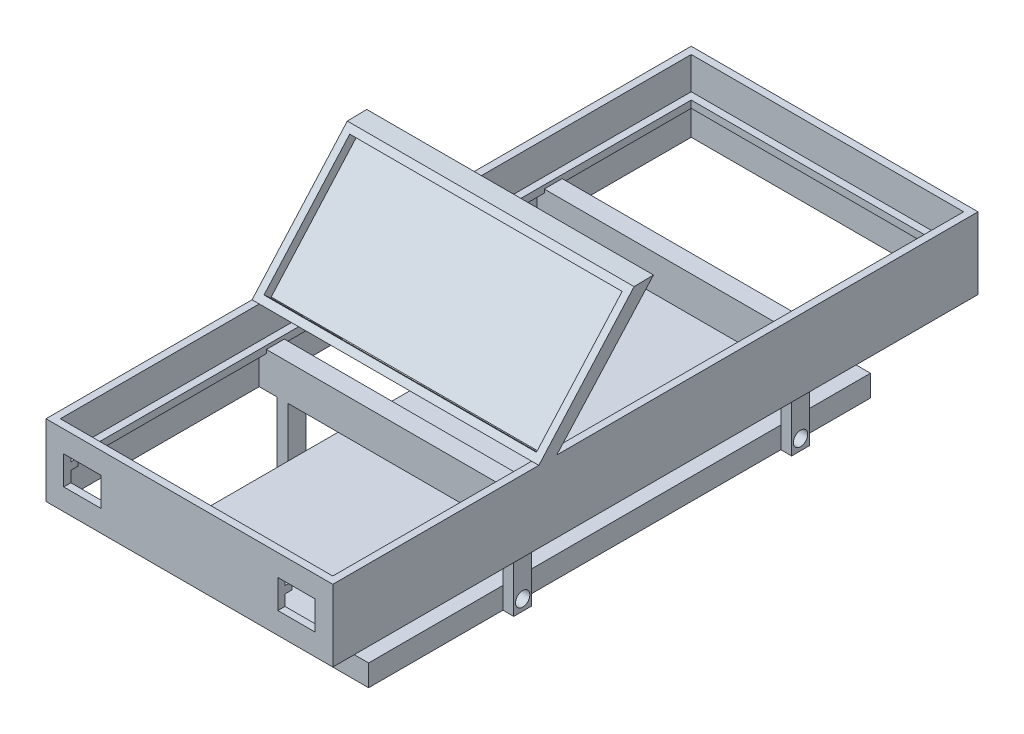
from build123d import *

# Parameters (mm, degrees)
SKETCH1_W            = 101.6
SKETCH1_H            = 50.8
BOSS_EXTRUDE1_DEPTH  = 228.6
SKETCH2_W            = 96.52
SKETCH2_H            = 172.72
CUT_EXTRUDE1_DEPTH   = 50.8
BOSS_EXTRUDE2_DEPTH  = 50.8
BOSS_EXTRUDE3_DEPTH  = 101.6
SKETCH13_W           = 96.52
SKETCH13_H           = 25.4
CUT_EXTRUDE2_DEPTH   = 50.8
SKETCH14_W           = 96.52
SKETCH14_H           = 25.4
CUT_EXTRUDE3_DEPTH   = 50.8
SKETCH15_W           = 96.52
SKETCH15_H           = 50.8
CUT_EXTRUDE6_DEPTH   = 6.35
SKETCH16_W           = 96.52
SKETCH16_H           = 45.72
CUT_EXTRUDE7_DEPTH   = 3.175
SKETCH17_W           = 101.6
SKETCH17_H           = 25.4
CUT_EXTRUDE8_DEPTH   = 228.6
SKETCH19_W           = 6.35
SKETCH19_H           = 12.7
BOSS_EXTRUDE4_DEPTH  = 96.52
SKETCH20_W           = 6.35
SKETCH20_H           = 12.7
BOSS_EXTRUDE5_DEPTH  = 101.6
SKETCH24_W           = 12.7
SKETCH24_H           = 6.35
BOSS_EXTRUDE8_DEPTH  = 19.05
SKETCH25_W           = 12.7
SKETCH25_H           = 6.35
BOSS_EXTRUDE9_DEPTH  = 19.05
SKETCH26_W           = 12.7
SKETCH26_H           = 6.35
BOSS_EXTRUDE10_DEPTH = 19.05
SKETCH27_W           = 12.7
SKETCH27_H           = 6.35
BOSS_EXTRUDE11_DEPTH = 19.05
SKETCH28_W           = 8.89
SKETCH28_H           = 19.05
CUT_EXTRUDE9_DEPTH   = 6.35
SKETCH29_W           = 8.89
SKETCH29_H           = 19.05
CUT_EXTRUDE10_DEPTH  = 6.35
SKETCH30_W           = 8.89
SKETCH30_H           = 19.05
CUT_EXTRUDE11_DEPTH  = 6.35
SKETCH31_W           = 8.89
SKETCH31_H           = 19.05
CUT_EXTRUDE12_DEPTH  = 6.35
SKETCH33_W           = 96.52
SKETCH33_H           = 2.54
BOSS_EXTRUDE13_DEPTH = 2.54
SKETCH34_W           = 96.52
SKETCH34_H           = 2.54
BOSS_EXTRUDE17_DEPTH = 2.54
SKETCH36_W           = 218.44
SKETCH36_H           = 2.54
BOSS_EXTRUDE18_DEPTH = 2.54
SKETCH37_W           = 218.44
SKETCH37_H           = 2.54
BOSS_EXTRUDE19_DEPTH = 2.54
SKETCH42_W           = 6.35
SKETCH42_H           = 6.35
CUT_EXTRUDE16_DEPTH  = 5.08
SKETCH45_W           = 13.208
SKETCH45_H           = 10.16
CUT_EXTRUDE19_DEPTH  = 6.35
SKETCH50_W           = 6.35
SKETCH50_H           = 6.35
BOSS_EXTRUDE20_DEPTH = 3.81
SKETCH51_W           = 6.35
SKETCH51_H           = 6.35
BOSS_EXTRUDE21_DEPTH = 3.81
SKETCH52_W           = 6.35
SKETCH52_H           = 6.35
BOSS_EXTRUDE22_DEPTH = 3.81
SKETCH53_W           = 6.35
SKETCH53_H           = 6.35
BOSS_EXTRUDE23_DEPTH = 3.81
SKETCH54_W           = 6.35
SKETCH54_H           = 6.35
BOSS_EXTRUDE24_DEPTH = 3.81
SKETCH55_W           = 76.2
SKETCH55_H           = 177.8
BOSS_EXTRUDE25_DEPTH = 7.62
SKETCH56_R           = 2.54
CUT_EXTRUDE20_DEPTH  = 83.82
SKETCH57_R           = 2.54
CUT_EXTRUDE21_DEPTH  = 83.82


with BuildPart() as part:
    # Sketch1 → Boss-Extrude1 (new body)
    with BuildSketch(Plane.XY):
        Rectangle(SKETCH1_W, SKETCH1_H)
    extrude(amount=-BOSS_EXTRUDE1_DEPTH)

    # Sketch2 → Cut-Extrude1 (cut)
    with BuildSketch(Plane(origin=(0, 25.4, 0), x_dir=(1, 0, 0), z_dir=(0, 1, 0))):
        with Locations((0, 114.3)):
            Rectangle(SKETCH2_W, SKETCH2_H)
    extrude(amount=-CUT_EXTRUDE1_DEPTH, mode=Mode.SUBTRACT)

    # Sketch3 → Boss-Extrude2 (add)
    with BuildSketch(Plane(origin=(0, 25.4, 0), x_dir=(1, 0, 0), z_dir=(0, 1, 0))):
        Polygon((48.26, 73.001295984), (48.26, 79.351295984), (-48.26, 79.351295984), (-48.26, 73.001295984), (0, 73.001295984), align=None)
    extrude(amount=-BOSS_EXTRUDE2_DEPTH)

    # Sketch11 → Boss-Extrude3 (add)
    with BuildSketch(Plane.ZY.offset(50.8)):
        Polygon((-79.351295984, 25.4), (-113.622558301, 63.5), (-106.756614843, 63.363382999), (-73.001295984, 25.4), align=None)
    extrude(amount=-BOSS_EXTRUDE3_DEPTH)

    # Sketch13 → Cut-Extrude2 (cut)
    with BuildSketch(Plane(origin=(0, 25.4, 0), x_dir=(1, 0, 0), z_dir=(0, 1, 0))):
        with Locations((0, 213.36)):
            Rectangle(SKETCH13_W, SKETCH13_H)
    extrude(amount=-CUT_EXTRUDE2_DEPTH, mode=Mode.SUBTRACT)

    # Sketch14 → Cut-Extrude3 (cut)
    with BuildSketch(Plane(origin=(0, 25.4, 0), x_dir=(1, 0, 0), z_dir=(0, 1, 0))):
        with Locations((0, 15.24)):
            Rectangle(SKETCH14_W, SKETCH14_H)
    extrude(amount=-CUT_EXTRUDE3_DEPTH, mode=Mode.SUBTRACT)

    # Sketch15 → Cut-Extrude6 (cut)
    with BuildSketch(Plane.XY.offset(-73.001295984)):
        Rectangle(SKETCH15_W, SKETCH15_H)
    extrude(amount=-CUT_EXTRUDE6_DEPTH, mode=Mode.SUBTRACT)

    # Sketch16 → Cut-Extrude7 (cut)
    with BuildSketch(Plane(origin=(0, -25.035409247, -28.156416881), x_dir=(1, 0, 0), z_dir=(0, 0.664474781, 0.747310689))):
        with Locations((0, 92.889211639)):
            Rectangle(SKETCH16_W, SKETCH16_H)
    extrude(amount=-CUT_EXTRUDE7_DEPTH, mode=Mode.SUBTRACT)

    # Sketch17 → Cut-Extrude8 (cut)
    with BuildSketch(Plane.XY):
        with Locations((0, -12.7)):
            Rectangle(SKETCH17_W, SKETCH17_H)
    extrude(amount=-CUT_EXTRUDE8_DEPTH, mode=Mode.SUBTRACT)

    # Sketch19 → Boss-Extrude4 (add)
    with BuildSketch(Plane.ZY.offset(-48.26)):
        with Locations((-76.176295984, 6.35)):
            Rectangle(SKETCH19_W, SKETCH19_H)
    extrude(amount=BOSS_EXTRUDE4_DEPTH)

    # Sketch20 → Boss-Extrude5 (add)
    with BuildSketch(Plane.ZY.offset(50.8)):
        with Locations((-174.625, 6.35)):
            Rectangle(SKETCH20_W, SKETCH20_H)
    extrude(amount=-BOSS_EXTRUDE5_DEPTH)

    # Sketch24 → Boss-Extrude8 (add)
    with BuildSketch(Plane.XZ):
        with Locations((44.45, -76.176295984)):
            Rectangle(SKETCH24_W, SKETCH24_H)
    extrude(amount=BOSS_EXTRUDE8_DEPTH)

    # Sketch25 → Boss-Extrude9 (add)
    with BuildSketch(Plane.XZ):
        with Locations((-44.45, -76.176295984)):
            Rectangle(SKETCH25_W, SKETCH25_H)
    extrude(amount=BOSS_EXTRUDE9_DEPTH)

    # Sketch26 → Boss-Extrude10 (add)
    with BuildSketch(Plane.XZ):
        with Locations((-44.45, -174.625)):
            Rectangle(SKETCH26_W, SKETCH26_H)
    extrude(amount=BOSS_EXTRUDE10_DEPTH)

    # Sketch27 → Boss-Extrude11 (add)
    with BuildSketch(Plane.XZ):
        with Locations((44.45, -174.625)):
            Rectangle(SKETCH27_W, SKETCH27_H)
    extrude(amount=BOSS_EXTRUDE11_DEPTH)

    # Sketch28 → Cut-Extrude9 (cut)
    with BuildSketch(Plane.XY.offset(-73.001295984)):
        with Locations((46.355, -9.525)):
            Rectangle(SKETCH28_W, SKETCH28_H)
    extrude(amount=-CUT_EXTRUDE9_DEPTH, mode=Mode.SUBTRACT)

    # Sketch29 → Cut-Extrude10 (cut)
    with BuildSketch(Plane.XY.offset(-73.001295984)):
        with Locations((-46.355, -9.525)):
            Rectangle(SKETCH29_W, SKETCH29_H)
    extrude(amount=-CUT_EXTRUDE10_DEPTH, mode=Mode.SUBTRACT)

    # Sketch30 → Cut-Extrude11 (cut)
    with BuildSketch(Plane.XY.offset(-171.45)):
        with Locations((-46.355, -9.525)):
            Rectangle(SKETCH30_W, SKETCH30_H)
    extrude(amount=-CUT_EXTRUDE11_DEPTH, mode=Mode.SUBTRACT)

    # Sketch31 → Cut-Extrude12 (cut)
    with BuildSketch(Plane.XY.offset(-171.45)):
        with Locations((46.355, -9.525)):
            Rectangle(SKETCH31_W, SKETCH31_H)
    extrude(amount=-CUT_EXTRUDE12_DEPTH, mode=Mode.SUBTRACT)

    # Sketch33 → Boss-Extrude13 (add)
    with BuildSketch(Plane(origin=(0, 0, -2.54), x_dir=(-1, 0, 0), z_dir=(0, 0, -1))):
        with Locations((0, 12.7)):
            Rectangle(SKETCH33_W, SKETCH33_H)
    extrude(amount=BOSS_EXTRUDE13_DEPTH)

    # Sketch34 → Boss-Extrude17 (add)
    with BuildSketch(Plane.XY.offset(-226.06)):
        with Locations((0, 12.7)):
            Rectangle(SKETCH34_W, SKETCH34_H)
    extrude(amount=BOSS_EXTRUDE17_DEPTH)

    # Sketch36 → Boss-Extrude18 (add)
    with BuildSketch(Plane(origin=(-48.26, 0, 0), x_dir=(0, 0, -1), z_dir=(1, 0, 0))):
        with Locations((114.3, 12.7)):
            Rectangle(SKETCH36_W, SKETCH36_H)
    extrude(amount=BOSS_EXTRUDE18_DEPTH)

    # Sketch37 → Boss-Extrude19 (add)
    with BuildSketch(Plane.ZY.offset(-48.26)):
        with Locations((-114.3, 12.7)):
            Rectangle(SKETCH37_W, SKETCH37_H)
    extrude(amount=BOSS_EXTRUDE19_DEPTH)

    # Sketch42 → Cut-Extrude16 (cut)
    with BuildSketch(Plane.ZY.offset(41.91)):
        with Locations((-76.176295984, -15.875)):
            Rectangle(SKETCH42_W, SKETCH42_H)
    extrude(amount=-CUT_EXTRUDE16_DEPTH, mode=Mode.SUBTRACT)

    # Sketch45 → Cut-Extrude19 (cut)
    with BuildSketch(Plane.XY):
        with Locations((37.933039121, 12.7)):
            Rectangle(SKETCH45_W, SKETCH45_H)
        with Locations((-37.933039121, 12.7)):
            Rectangle(SKETCH45_W, SKETCH45_H)
    extrude(amount=-CUT_EXTRUDE19_DEPTH, mode=Mode.SUBTRACT)

    # Sketch50 → Boss-Extrude20 (add)
    with BuildSketch(Plane.ZY.offset(41.91)):
        with Locations((-76.176295984, -15.875)):
            Rectangle(SKETCH50_W, SKETCH50_H)
    extrude(amount=-BOSS_EXTRUDE20_DEPTH)

    # Sketch51 → Boss-Extrude21 (add)
    with BuildSketch(Plane.ZY.offset(41.91)):
        with Locations((-76.176295984, -22.225)):
            Rectangle(SKETCH51_W, SKETCH51_H)
    extrude(amount=-BOSS_EXTRUDE21_DEPTH)

    # Sketch52 → Boss-Extrude22 (add)
    with BuildSketch(Plane.ZY.offset(41.91)):
        with Locations((-174.625, -22.225)):
            Rectangle(SKETCH52_W, SKETCH52_H)
    extrude(amount=-BOSS_EXTRUDE22_DEPTH)

    # Sketch53 → Boss-Extrude23 (add)
    with BuildSketch(Plane(origin=(41.91, 0, 0), x_dir=(0, 0, -1), z_dir=(1, 0, 0))):
        with Locations((76.176295984, -22.225)):
            Rectangle(SKETCH53_W, SKETCH53_H)
    extrude(amount=-BOSS_EXTRUDE23_DEPTH)

    # Sketch54 → Boss-Extrude24 (add)
    with BuildSketch(Plane(origin=(41.91, 0, 0), x_dir=(0, 0, -1), z_dir=(1, 0, 0))):
        with Locations((174.625, -22.225)):
            Rectangle(SKETCH54_W, SKETCH54_H)
    extrude(amount=-BOSS_EXTRUDE24_DEPTH)

    # Sketch55 → Boss-Extrude25 (add)
    with BuildSketch(Plane.XZ.offset(25.4)):
        with Locations((0, -114.3)):
            Rectangle(SKETCH55_W, SKETCH55_H)
    extrude(amount=-BOSS_EXTRUDE25_DEPTH)

    # Sketch56 → Cut-Extrude20 (cut)
    with BuildSketch(Plane.ZY.offset(41.91)):
        with Locations((-76.176295984, -21.59)):
            Circle(SKETCH56_R)
    extrude(amount=-CUT_EXTRUDE20_DEPTH, mode=Mode.SUBTRACT)

    # Sketch57 → Cut-Extrude21 (cut)
    with BuildSketch(Plane.ZY.offset(41.91)):
        with Locations((-174.625, -21.59)):
            Circle(SKETCH57_R)
    extrude(amount=-CUT_EXTRUDE21_DEPTH, mode=Mode.SUBTRACT)


solid = part.part
